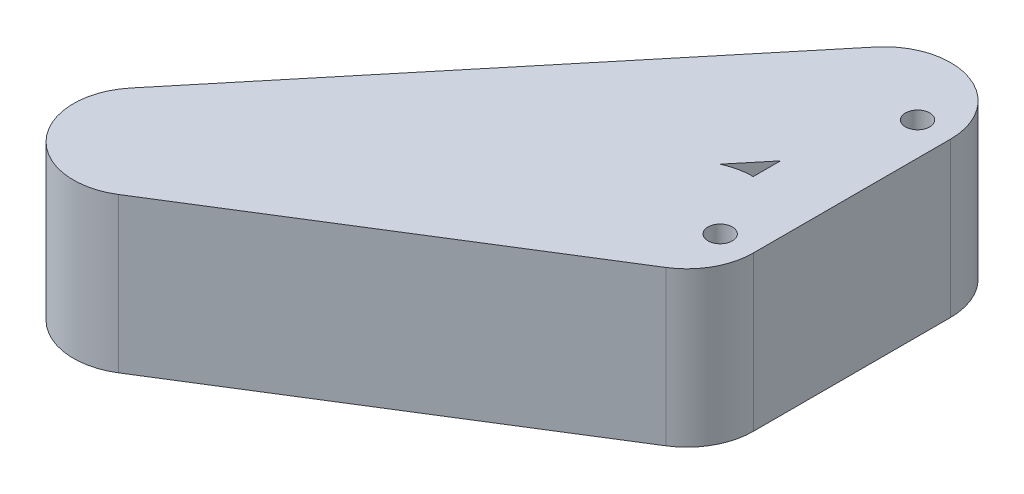
from build123d import *

# Parameters (mm, degrees)
SKETCH1_R           = 2.75
BOSS_EXTRUDE1_DEPTH = 35
SKETCH2_R           = 2.75
BOSS_EXTRUDE2_DEPTH = 35


with BuildPart() as part:
    # Sketch1 → Boss-Extrude1 (new body)
    with BuildSketch(Plane(origin=(0, 0, 0), x_dir=(1, 0, 0), z_dir=(0, 1, 0))):
        with BuildLine():
            Line((7.5, 44.72), (7.5, 0))
            ThreePointArc((7.5, 0), (0, -7.5), (-7.5, 0))
            Line((-7.5, 0), (-7.5, 44.72))
            ThreePointArc((-7.5, 44.72), (0, 52.22), (7.5, 44.72))
        make_face()
        with Locations((0, 44.72)):
            Circle(SKETCH1_R, mode=Mode.SUBTRACT)
        Circle(SKETCH1_R, mode=Mode.SUBTRACT)
    extrude(amount=BOSS_EXTRUDE1_DEPTH)

    # Sketch2 → Boss-Extrude2 (add)
    with BuildSketch(Plane.XZ):
        with BuildLine():
            ThreePointArc((-75.875539691, 60.413455223), (-95.106545537, 57.577650686), (-95.38977649, 38.140748838))
            Line((-95.38977649, 38.140748838), (-19.065447836, -54.271984943))
            ThreePointArc((-19.065447836, -54.271984943), (2.051984943, -56.285447836), (4.065447836, -35.168015057))
            Line((4.065447836, -35.168015057), (-13.698799918, -13.659241545))
            ThreePointArc((-13.698799918, -13.659241545), (5.718972245, -7.089342197), (0.448788963, 12.720721442))
            Line((0.448788963, 12.720721442), (-75.875539691, 60.413455223))
        make_face()
        Circle(SKETCH2_R, mode=Mode.SUBTRACT)
        with Locations((0, -44.72)):
            Circle(SKETCH2_R, mode=Mode.SUBTRACT)
    extrude(amount=-BOSS_EXTRUDE2_DEPTH)


solid = part.part
